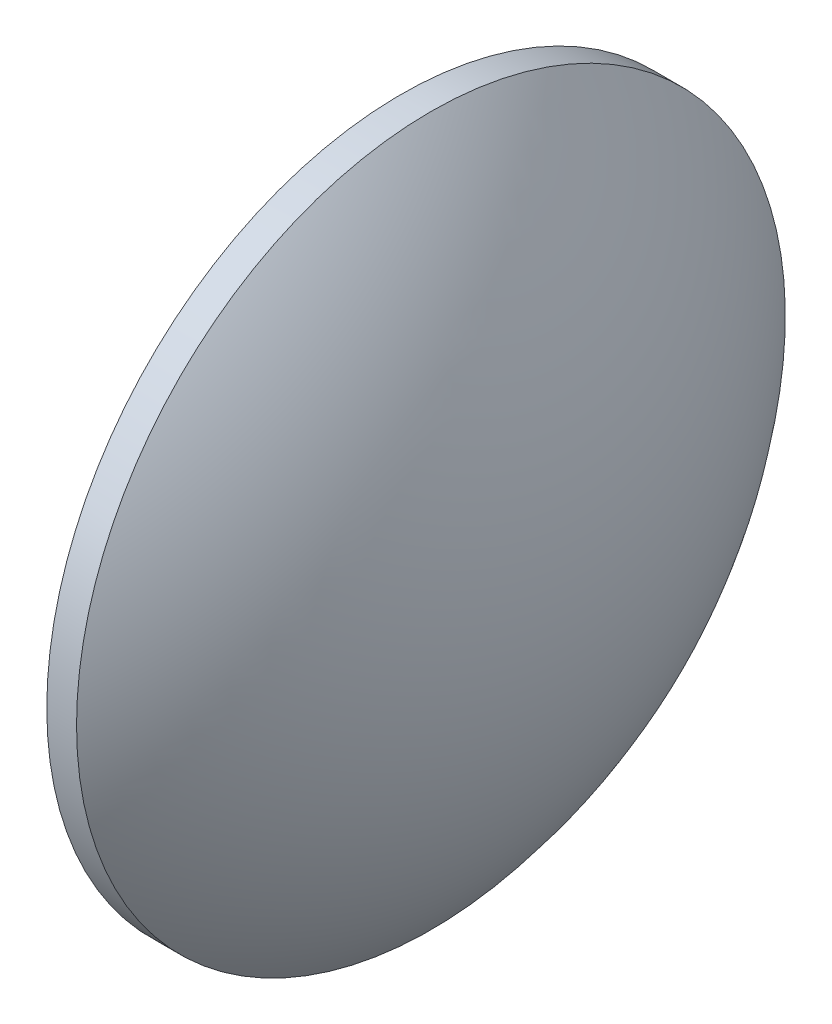
from build123d import *


with BuildPart() as part:
    # 草图1 → 旋转1 (revolve)
    with BuildSketch(Plane.XY):
        with BuildLine():
            Line((501.567527699, 160.83422707), (501.567527699, 170.83422707))
            Line((501.567527699, 170.83422707), (502.407527699, 170.83422707))
            ThreePointArc((502.407527699, 170.83422707), (505.123780451, 166.158595577), (506.067527699, 160.83422707))
            Line((506.067527699, 160.83422707), (501.567527699, 160.83422707))
        make_face()
    revolve(axis=Axis((496.910941924, 160.83422707, 0), (1, 0, 0)))


solid = part.part
